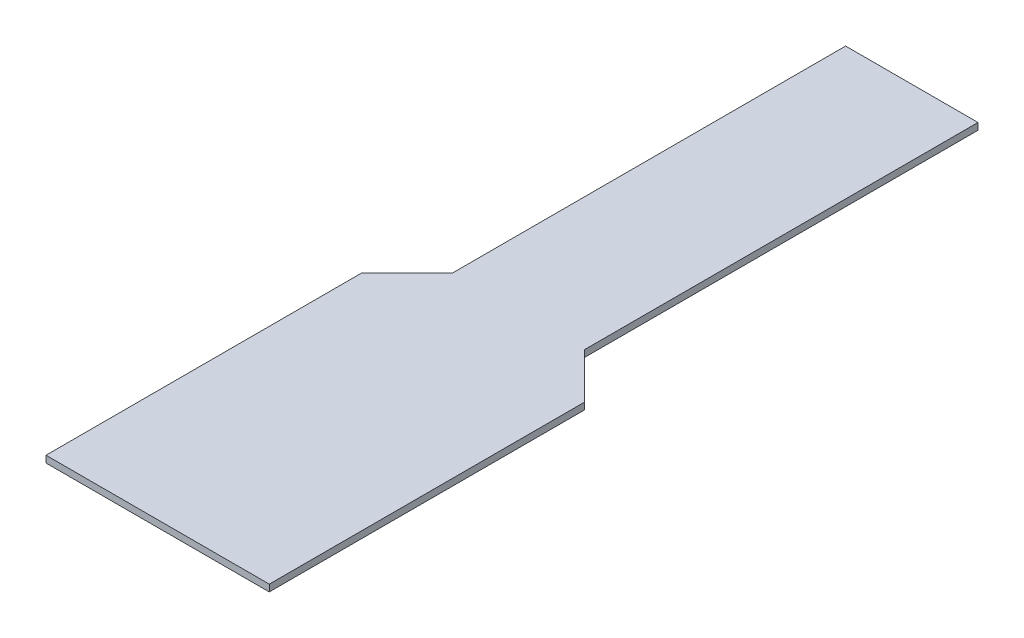
from build123d import *

# Parameters (mm, degrees)
BOSS_EXTRUDE1_DEPTH = 0.635


with BuildPart() as part:
    # Sketch1 → Boss-Extrude1 (new body)
    with BuildSketch(Plane(origin=(0, 0, 0), x_dir=(1, 0, 0), z_dir=(0, 1, 0))):
        Polygon((-6.1976, 0), (6.1976, 0), (6.1976, -36.83), (10.4521, -41.0845), (10.4521, -70.612), (-10.4521, -70.612), (-10.4521, -41.0845), (-6.1976, -36.83), align=None)
    extrude(amount=BOSS_EXTRUDE1_DEPTH)


solid = part.part
